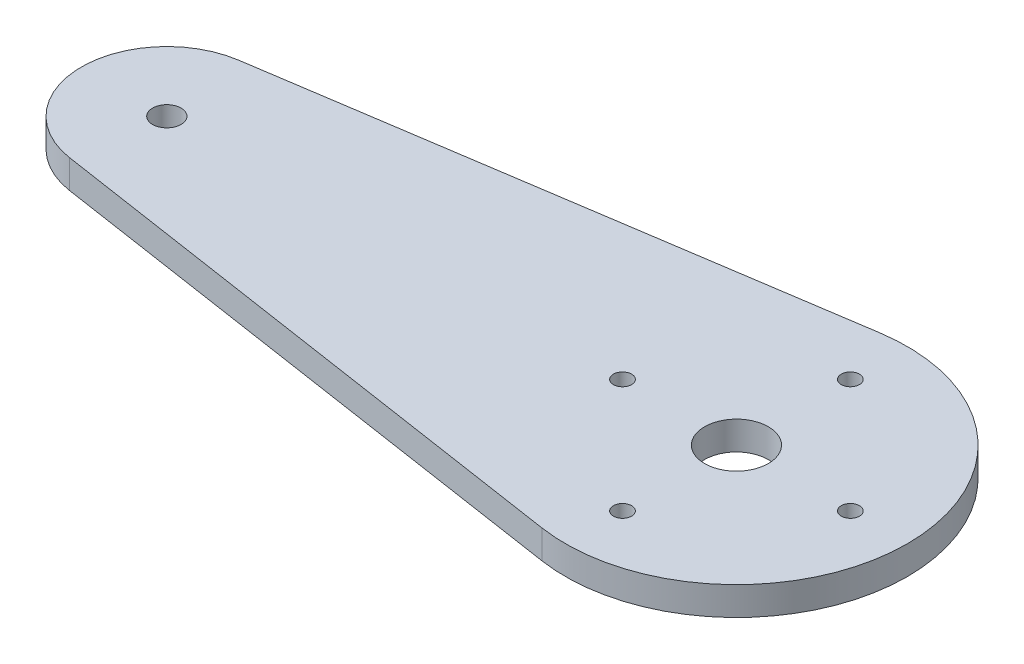
from build123d import *

# Parameters (mm, degrees)
SKETCH1_R           = 1.5875
SKETCH1_R_2         = 3.556
SKETCH1_R_3         = 1.016
BOSS_EXTRUDE1_DEPTH = 3.175


with BuildPart() as part:
    # Sketch1 → Boss-Extrude1 (new body)
    with BuildSketch(Plane(origin=(0, 0, 0), x_dir=(1, 0, 0), z_dir=(0, 1, 0))):
        with BuildLine():
            Line((-64.92875, 9.417234118), (-2.8575, 18.834468236))
            ThreePointArc((-2.8575, 18.834468236), (19.05, 0), (-2.8575, -18.834468236))
            Line((-2.8575, -18.834468236), (-64.92875, -9.417234118))
            ThreePointArc((-64.92875, -9.417234118), (-73.025, 0), (-64.92875, 9.417234118))
        make_face()
        with Locations((-63.5, 0)):
            Circle(SKETCH1_R, mode=Mode.SUBTRACT)
        Circle(SKETCH1_R_2, mode=Mode.SUBTRACT)
        with Locations((0, 12.7)):
            Circle(SKETCH1_R_3, mode=Mode.SUBTRACT)
        with Locations((12.7, 0)):
            Circle(SKETCH1_R_3, mode=Mode.SUBTRACT)
        with Locations((0, -12.7)):
            Circle(SKETCH1_R_3, mode=Mode.SUBTRACT)
        with Locations((-12.7, 0)):
            Circle(SKETCH1_R_3, mode=Mode.SUBTRACT)
    extrude(amount=BOSS_EXTRUDE1_DEPTH)


solid = part.part
